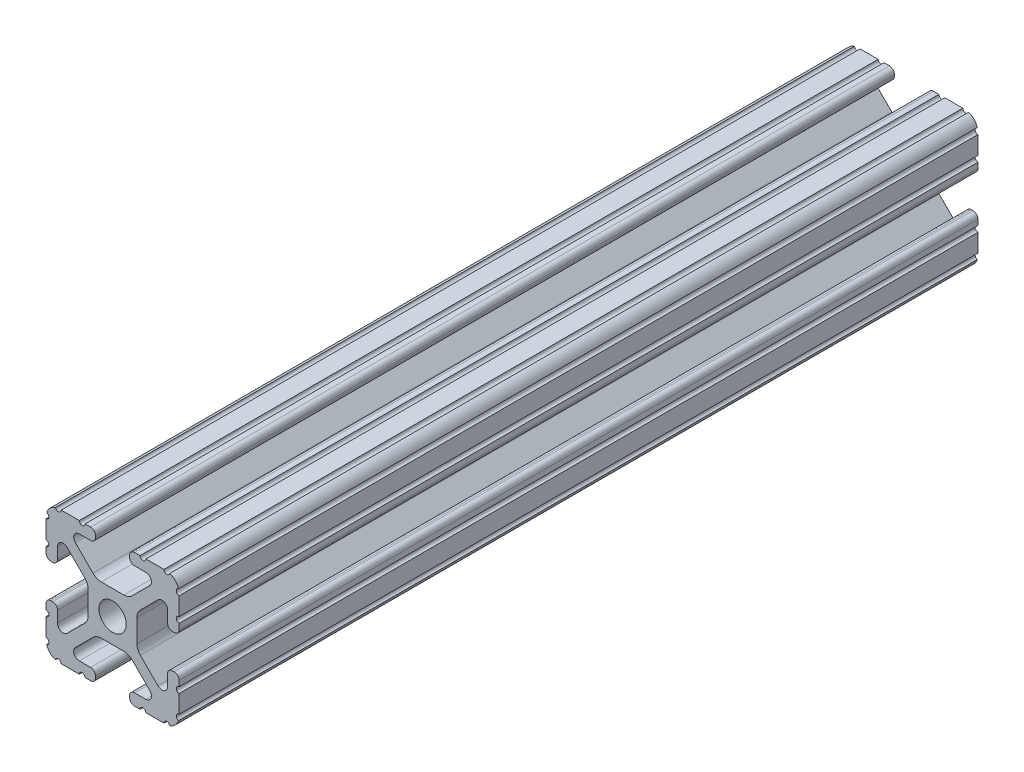
from build123d import *

# Parameters (mm, degrees)
BOSS_EXTRUDE1_DEPTH     = 76.2
SKETCH5_R               = 0.55245
CUT_EXTRUDE1_DEPTH      = 77.2
CUT_EXTRUDE1_DEPTH_BACK = 77.2
SKETCH6_R               = 2.555
CUT_EXTRUDE2_DEPTH      = 13.7
CUT_EXTRUDE2_DEPTH_BACK = 13.7


with BuildPart() as part:
    # Sketch4 → Boss-Extrude1 (new body, symmetric)
    with BuildSketch(Plane.XY):
        with BuildLine():
            Line((4.190365, -12.7), (10.11729625, -12.7))
            ThreePointArc((10.11729625, -12.7), (11.943543585, -11.943543585), (12.7, -10.11729625))
            Line((12.7, -10.11729625), (12.7, -4.190365))
            ThreePointArc((12.7, -4.190365), (12.42492494, -3.52627506), (11.760835, -3.2512))
            Line((11.760835, -3.2512), (11.429365, -3.2512))
            ThreePointArc((11.429365, -3.2512), (10.76527506, -3.52627506), (10.4902, -4.190365))
            Line((10.4902, -4.190365), (10.4902, -6.348478019))
            ThreePointArc((10.4902, -6.348478019), (9.830707141, -7.335478831), (8.666460301, -7.103895736))
            Line((8.666460301, -7.103895736), (5.299899128, -3.737334563))
            ThreePointArc((5.299899128, -3.737334563), (4.817571085, -3.015479634), (4.6482, -2.16399369))
            Line((4.6482, -2.16399369), (4.6482, 0))
            Line((4.6482, 0), (2.6035, 0))
            ThreePointArc((2.6035, 0), (1.840952505, -1.840952505), (0, -2.6035))
            Line((0, -2.6035), (0, -4.6482))
            Line((0, -4.6482), (2.16399369, -4.6482))
            ThreePointArc((2.16399369, -4.6482), (3.015479634, -4.817571085), (3.737334563, -5.299899128))
            Line((3.737334563, -5.299899128), (7.103895736, -8.666460301))
            ThreePointArc((7.103895736, -8.666460301), (7.335478831, -9.830707141), (6.348478019, -10.4902))
            Line((6.348478019, -10.4902), (4.190365, -10.4902))
            ThreePointArc((4.190365, -10.4902), (3.52627506, -10.76527506), (3.2512, -11.429365))
            Line((3.2512, -11.429365), (3.2512, -11.760835))
            ThreePointArc((3.2512, -11.760835), (3.52627506, -12.42492494), (4.190365, -12.7))
        make_face()
    extrude(amount=BOSS_EXTRUDE1_DEPTH, both=True)

    # Sketch5 → Cut-Extrude1 (cut, two sides)
    with BuildSketch(Plane.XY) as cut_extrude1_sk:
        with Locations((10.356153152, -12.7)):
            Circle(SKETCH5_R)
        with Locations((5.796028019, -12.7)):
            Circle(SKETCH5_R)
        with Locations((12.7, -10.356153152)):
            Circle(SKETCH5_R)
        with Locations((12.7, -5.796028019)):
            Circle(SKETCH5_R)
    extrude(amount=CUT_EXTRUDE1_DEPTH, mode=Mode.SUBTRACT)
    extrude(cut_extrude1_sk.sketch, amount=-CUT_EXTRUDE1_DEPTH_BACK, mode=Mode.SUBTRACT)

    # Mirror1: part across plane


with BuildPart() as part_1:
    add(part.part)
    add(part.part.mirror(Plane(origin=(0, 0, 0), x_dir=(0, 0, 1), z_dir=(1, 0, 0))))

    # Mirror2: part across plane


with BuildPart() as part_2:
    add(part_1.part)
    add(part_1.part.mirror(Plane.ZX))

    # Sketch6 → Cut-Extrude2 (cut, two sides)
    with BuildSketch(Plane(origin=(0, 0, 0), x_dir=(1, 0, 0), z_dir=(0, 1, 0))) as cut_extrude2_sk:
        with Locations((0, -63.5)):
            Circle(SKETCH6_R)
        with Locations((0, 63.5)):
            Circle(SKETCH6_R)
    extrude(amount=CUT_EXTRUDE2_DEPTH, mode=Mode.SUBTRACT)
    extrude(cut_extrude2_sk.sketch, amount=-CUT_EXTRUDE2_DEPTH_BACK, mode=Mode.SUBTRACT)


solid = part_2.part
